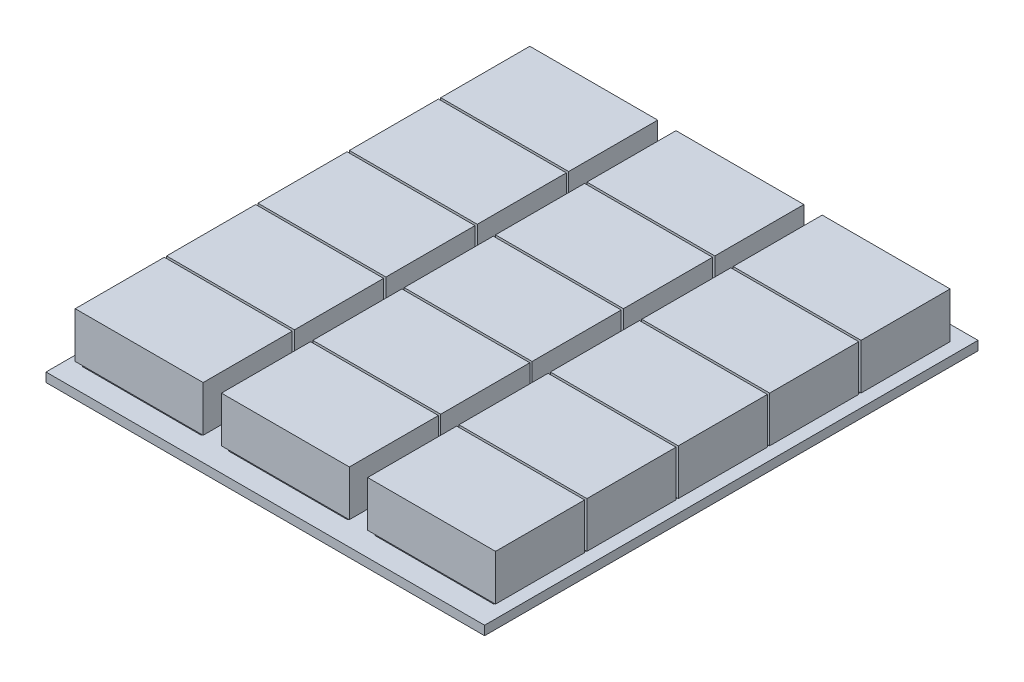
from build123d import *

# Parameters (mm, degrees)
SKETCH1_W                  = 80
SKETCH1_H                  = 270
BOSS_EXTRUDE1_DEPTH        = 5
SKETCH2_W                  = 65
SKETCH2_H                  = 45
BOSS_EXTRUDE3_DEPTH        = 2
LPATTERN1_COUNT            = 5
LPATTERN1_PITCH            = 50
SKETCH3_W                  = 70
SKETCH3_H                  = 48.748964222
BOSS_EXTRUDE8_DEPTH        = 25
LPATTERN5_COUNT            = 5
LPATTERN5_PITCH            = 50
LPATTERN6_COUNT            = 3
LPATTERN6_PITCH            = 80
LPATTERN6_COPY_1_SKETCH_W  = 65
LPATTERN6_COPY_1_SKETCH_H  = 45
LPATTERN6_COPY_1_DEPTH     = 2
LPATTERN6_COPY_2_SKETCH_W  = 65
LPATTERN6_COPY_2_SKETCH_H  = 45
LPATTERN6_COPY_2_DEPTH     = 2
LPATTERN6_COPY_3_SKETCH_W  = 65
LPATTERN6_COPY_3_SKETCH_H  = 45
LPATTERN6_COPY_3_DEPTH     = 2
LPATTERN6_COPY_4_SKETCH_W  = 65
LPATTERN6_COPY_4_SKETCH_H  = 45
LPATTERN6_COPY_4_DEPTH     = 2
LPATTERN6_COPY_5_SKETCH_W  = 65
LPATTERN6_COPY_5_SKETCH_H  = 45
LPATTERN6_COPY_5_DEPTH     = 2
LPATTERN6_COPY_6_SKETCH_W  = 65
LPATTERN6_COPY_6_SKETCH_H  = 45
LPATTERN6_COPY_6_DEPTH     = 2
LPATTERN6_COPY_7_SKETCH_W  = 65
LPATTERN6_COPY_7_SKETCH_H  = 45
LPATTERN6_COPY_7_DEPTH     = 2
LPATTERN6_COPY_8_SKETCH_W  = 65
LPATTERN6_COPY_8_SKETCH_H  = 45
LPATTERN6_COPY_8_DEPTH     = 2
LPATTERN6_COPY_9_SKETCH_W  = 70
LPATTERN6_COPY_9_SKETCH_H  = 48.748964222
LPATTERN6_COPY_9_DEPTH     = 25
LPATTERN6_COPY_10_SKETCH_W = 70
LPATTERN6_COPY_10_SKETCH_H = 48.748964222
LPATTERN6_COPY_10_DEPTH    = 25
LPATTERN6_COPY_11_SKETCH_W = 70
LPATTERN6_COPY_11_SKETCH_H = 48.748964222
LPATTERN6_COPY_11_DEPTH    = 25
LPATTERN6_COPY_12_SKETCH_W = 70
LPATTERN6_COPY_12_SKETCH_H = 48.748964222
LPATTERN6_COPY_12_DEPTH    = 25
LPATTERN6_COPY_13_SKETCH_W = 70
LPATTERN6_COPY_13_SKETCH_H = 48.748964222
LPATTERN6_COPY_13_DEPTH    = 25
LPATTERN6_COPY_14_SKETCH_W = 70
LPATTERN6_COPY_14_SKETCH_H = 48.748964222
LPATTERN6_COPY_14_DEPTH    = 25
LPATTERN6_COPY_15_SKETCH_W = 70
LPATTERN6_COPY_15_SKETCH_H = 48.748964222
LPATTERN6_COPY_15_DEPTH    = 25
LPATTERN6_COPY_16_SKETCH_W = 70
LPATTERN6_COPY_16_SKETCH_H = 48.748964222
LPATTERN6_COPY_16_DEPTH    = 25


with BuildPart() as part:
    # Sketch1 → Boss-Extrude1 (new body)
    with BuildSketch(Plane(origin=(0, 0, 0), x_dir=(1, 0, 0), z_dir=(0, 1, 0))):
        Rectangle(SKETCH1_W, SKETCH1_H)
    boss_extrude1 = extrude(amount=BOSS_EXTRUDE1_DEPTH)

    # Sketch2 → Boss-Extrude3 (add)
    with BuildSketch(Plane(origin=(0, 5, 0), x_dir=(1, 0, 0), z_dir=(0, 1, 0))):
        with Locations((0, -100)):
            Rectangle(SKETCH2_W, SKETCH2_H)
    boss_extrude3 = extrude(amount=BOSS_EXTRUDE3_DEPTH)

    # LPattern1: Boss-Extrude3 ×5
    with Locations(*[(0, 0, -i * LPATTERN1_PITCH) for i in range(1, LPATTERN1_COUNT)]):
        add(boss_extrude3)

    # Sketch3 → Boss-Extrude8 (add)
    with BuildSketch(Plane(origin=(0, 7, 0), x_dir=(1, 0, 0), z_dir=(0, 1, 0))):
        with Locations((0, -99.635002086)):
            Rectangle(SKETCH3_W, SKETCH3_H)
    boss_extrude8 = extrude(amount=BOSS_EXTRUDE8_DEPTH)

    # LPattern5: Boss-Extrude8 ×5
    with Locations(*[(0, 0, -i * LPATTERN5_PITCH) for i in range(1, LPATTERN5_COUNT)]):
        add(boss_extrude8)

    # LPattern6: Boss-Extrude1, Boss-Extrude3, Boss-Extrude8 ×3
    with Locations(*[(-i * LPATTERN6_PITCH, 0, 0) for i in range(1, LPATTERN6_COUNT)]):
        add(boss_extrude1)
        add(boss_extrude3)
        add(boss_extrude8)

    # LPattern6 copy 1 sketch → LPattern6 copy 1 (add)
    with BuildSketch(Plane(origin=(-80, 5, -50), x_dir=(1, 0, 0), z_dir=(0, 1, 0))):
        with Locations((0, -100)):
            Rectangle(LPATTERN6_COPY_1_SKETCH_W, LPATTERN6_COPY_1_SKETCH_H)
    extrude(amount=LPATTERN6_COPY_1_DEPTH)

    # LPattern6 copy 2 sketch → LPattern6 copy 2 (add)
    with BuildSketch(Plane(origin=(-160, 5, -50), x_dir=(1, 0, 0), z_dir=(0, 1, 0))):
        with Locations((0, -100)):
            Rectangle(LPATTERN6_COPY_2_SKETCH_W, LPATTERN6_COPY_2_SKETCH_H)
    extrude(amount=LPATTERN6_COPY_2_DEPTH)

    # LPattern6 copy 3 sketch → LPattern6 copy 3 (add)
    with BuildSketch(Plane(origin=(-80, 5, -100), x_dir=(1, 0, 0), z_dir=(0, 1, 0))):
        with Locations((0, -100)):
            Rectangle(LPATTERN6_COPY_3_SKETCH_W, LPATTERN6_COPY_3_SKETCH_H)
    extrude(amount=LPATTERN6_COPY_3_DEPTH)

    # LPattern6 copy 4 sketch → LPattern6 copy 4 (add)
    with BuildSketch(Plane(origin=(-160, 5, -100), x_dir=(1, 0, 0), z_dir=(0, 1, 0))):
        with Locations((0, -100)):
            Rectangle(LPATTERN6_COPY_4_SKETCH_W, LPATTERN6_COPY_4_SKETCH_H)
    extrude(amount=LPATTERN6_COPY_4_DEPTH)

    # LPattern6 copy 5 sketch → LPattern6 copy 5 (add)
    with BuildSketch(Plane(origin=(-80, 5, -150), x_dir=(1, 0, 0), z_dir=(0, 1, 0))):
        with Locations((0, -100)):
            Rectangle(LPATTERN6_COPY_5_SKETCH_W, LPATTERN6_COPY_5_SKETCH_H)
    extrude(amount=LPATTERN6_COPY_5_DEPTH)

    # LPattern6 copy 6 sketch → LPattern6 copy 6 (add)
    with BuildSketch(Plane(origin=(-160, 5, -150), x_dir=(1, 0, 0), z_dir=(0, 1, 0))):
        with Locations((0, -100)):
            Rectangle(LPATTERN6_COPY_6_SKETCH_W, LPATTERN6_COPY_6_SKETCH_H)
    extrude(amount=LPATTERN6_COPY_6_DEPTH)

    # LPattern6 copy 7 sketch → LPattern6 copy 7 (add)
    with BuildSketch(Plane(origin=(-80, 5, -200), x_dir=(1, 0, 0), z_dir=(0, 1, 0))):
        with Locations((0, -100)):
            Rectangle(LPATTERN6_COPY_7_SKETCH_W, LPATTERN6_COPY_7_SKETCH_H)
    extrude(amount=LPATTERN6_COPY_7_DEPTH)

    # LPattern6 copy 8 sketch → LPattern6 copy 8 (add)
    with BuildSketch(Plane(origin=(-160, 5, -200), x_dir=(1, 0, 0), z_dir=(0, 1, 0))):
        with Locations((0, -100)):
            Rectangle(LPATTERN6_COPY_8_SKETCH_W, LPATTERN6_COPY_8_SKETCH_H)
    extrude(amount=LPATTERN6_COPY_8_DEPTH)

    # LPattern6 copy 9 sketch → LPattern6 copy 9 (add)
    with BuildSketch(Plane(origin=(-80, 7, -50), x_dir=(1, 0, 0), z_dir=(0, 1, 0))):
        with Locations((0, -99.635002086)):
            Rectangle(LPATTERN6_COPY_9_SKETCH_W, LPATTERN6_COPY_9_SKETCH_H)
    extrude(amount=LPATTERN6_COPY_9_DEPTH)

    # LPattern6 copy 10 sketch → LPattern6 copy 10 (add)
    with BuildSketch(Plane(origin=(-160, 7, -50), x_dir=(1, 0, 0), z_dir=(0, 1, 0))):
        with Locations((0, -99.635002086)):
            Rectangle(LPATTERN6_COPY_10_SKETCH_W, LPATTERN6_COPY_10_SKETCH_H)
    extrude(amount=LPATTERN6_COPY_10_DEPTH)

    # LPattern6 copy 11 sketch → LPattern6 copy 11 (add)
    with BuildSketch(Plane(origin=(-80, 7, -100), x_dir=(1, 0, 0), z_dir=(0, 1, 0))):
        with Locations((0, -99.635002086)):
            Rectangle(LPATTERN6_COPY_11_SKETCH_W, LPATTERN6_COPY_11_SKETCH_H)
    extrude(amount=LPATTERN6_COPY_11_DEPTH)

    # LPattern6 copy 12 sketch → LPattern6 copy 12 (add)
    with BuildSketch(Plane(origin=(-160, 7, -100), x_dir=(1, 0, 0), z_dir=(0, 1, 0))):
        with Locations((0, -99.635002086)):
            Rectangle(LPATTERN6_COPY_12_SKETCH_W, LPATTERN6_COPY_12_SKETCH_H)
    extrude(amount=LPATTERN6_COPY_12_DEPTH)

    # LPattern6 copy 13 sketch → LPattern6 copy 13 (add)
    with BuildSketch(Plane(origin=(-80, 7, -150), x_dir=(1, 0, 0), z_dir=(0, 1, 0))):
        with Locations((0, -99.635002086)):
            Rectangle(LPATTERN6_COPY_13_SKETCH_W, LPATTERN6_COPY_13_SKETCH_H)
    extrude(amount=LPATTERN6_COPY_13_DEPTH)

    # LPattern6 copy 14 sketch → LPattern6 copy 14 (add)
    with BuildSketch(Plane(origin=(-160, 7, -150), x_dir=(1, 0, 0), z_dir=(0, 1, 0))):
        with Locations((0, -99.635002086)):
            Rectangle(LPATTERN6_COPY_14_SKETCH_W, LPATTERN6_COPY_14_SKETCH_H)
    extrude(amount=LPATTERN6_COPY_14_DEPTH)

    # LPattern6 copy 15 sketch → LPattern6 copy 15 (add)
    with BuildSketch(Plane(origin=(-80, 7, -200), x_dir=(1, 0, 0), z_dir=(0, 1, 0))):
        with Locations((0, -99.635002086)):
            Rectangle(LPATTERN6_COPY_15_SKETCH_W, LPATTERN6_COPY_15_SKETCH_H)
    extrude(amount=LPATTERN6_COPY_15_DEPTH)

    # LPattern6 copy 16 sketch → LPattern6 copy 16 (add)
    with BuildSketch(Plane(origin=(-160, 7, -200), x_dir=(1, 0, 0), z_dir=(0, 1, 0))):
        with Locations((0, -99.635002086)):
            Rectangle(LPATTERN6_COPY_16_SKETCH_W, LPATTERN6_COPY_16_SKETCH_H)
    extrude(amount=LPATTERN6_COPY_16_DEPTH)


solid = part.part
